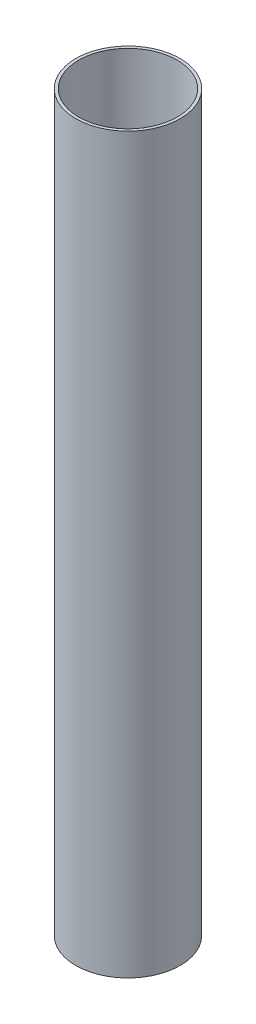
from build123d import *

# Parameters (mm, degrees)
SKETCH2_R           = 28.9052
SKETCH2_R_2         = 27.3304
BOSS_EXTRUDE1_DEPTH = 406.4


with BuildPart() as part:
    # Sketch2 → Boss-Extrude1 (new body)
    with BuildSketch(Plane(origin=(0, 0, 0), x_dir=(1, 0, 0), z_dir=(0, 1, 0))):
        Circle(SKETCH2_R)
        Circle(SKETCH2_R_2, mode=Mode.SUBTRACT)
    extrude(amount=BOSS_EXTRUDE1_DEPTH)


solid = part.part
